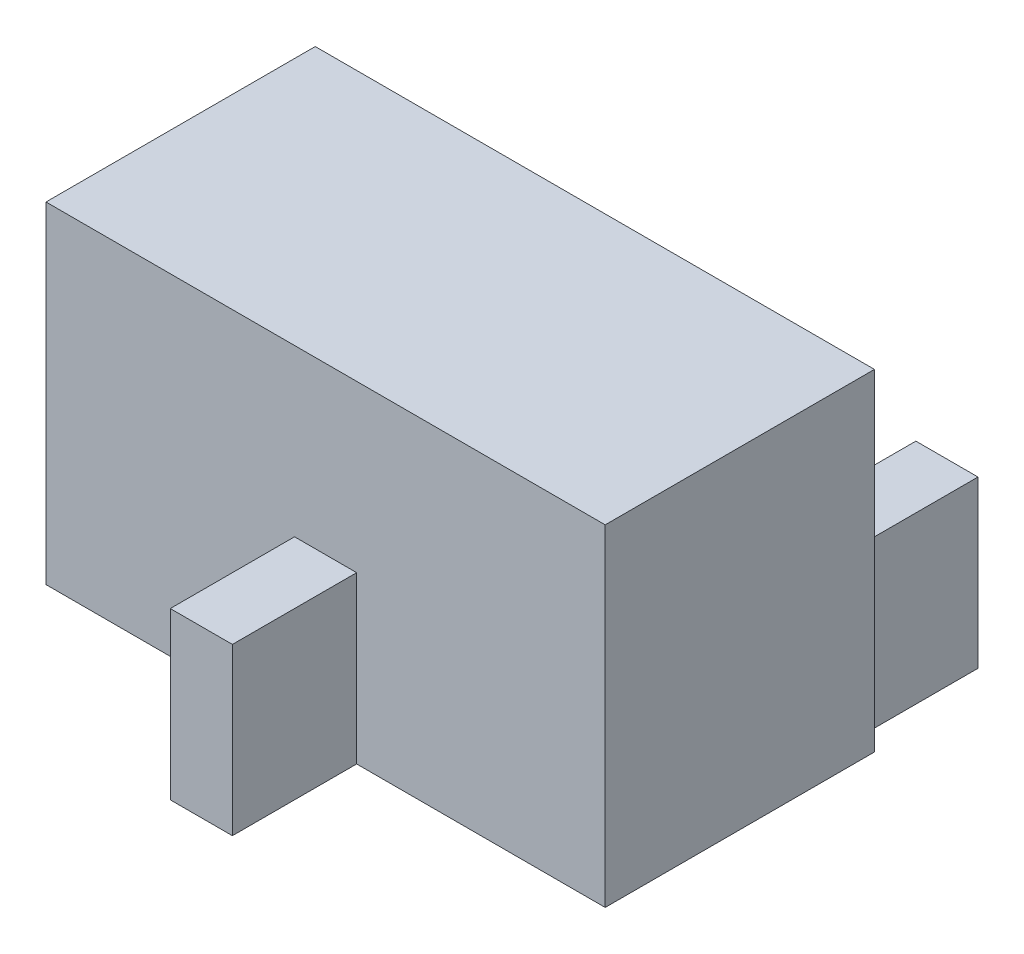
from build123d import *

# Parameters (mm, degrees)
SKETCH_1_W      = 2.7
SKETCH_1_H      = 1.3
EXTRUDE_1_DEPTH = 1.6
SKETCH_2_W      = 0.3
SKETCH_2_H      = 0.6
EXTRUDE_2_DEPTH = 0.8


with BuildPart() as part:
    # Эскиз1 → Бобышка-Вытянуть1 (new body)
    with BuildSketch(Plane(origin=(0, 0, 0), x_dir=(1, 0, 0), z_dir=(0, 1, 0))):
        with Locations((-0.462837838, -0.166891892)):
            Rectangle(SKETCH_1_W, SKETCH_1_H)
    extrude(amount=EXTRUDE_1_DEPTH)

    # Эскиз2 → Бобышка-Вытянуть2 (add)
    with BuildSketch(Plane(origin=(0, 0, 0), x_dir=(1, 0, 0), z_dir=(0, 1, 0))):
        with Locations((-1.562837838, 0.783108108)):
            Rectangle(SKETCH_2_W, SKETCH_2_H)
        with Locations((0.637162162, 0.783108108)):
            Rectangle(SKETCH_2_W, SKETCH_2_H)
        with Locations((-0.462837838, -1.116891892)):
            Rectangle(SKETCH_2_W, SKETCH_2_H)
    extrude(amount=EXTRUDE_2_DEPTH)


solid = part.part
